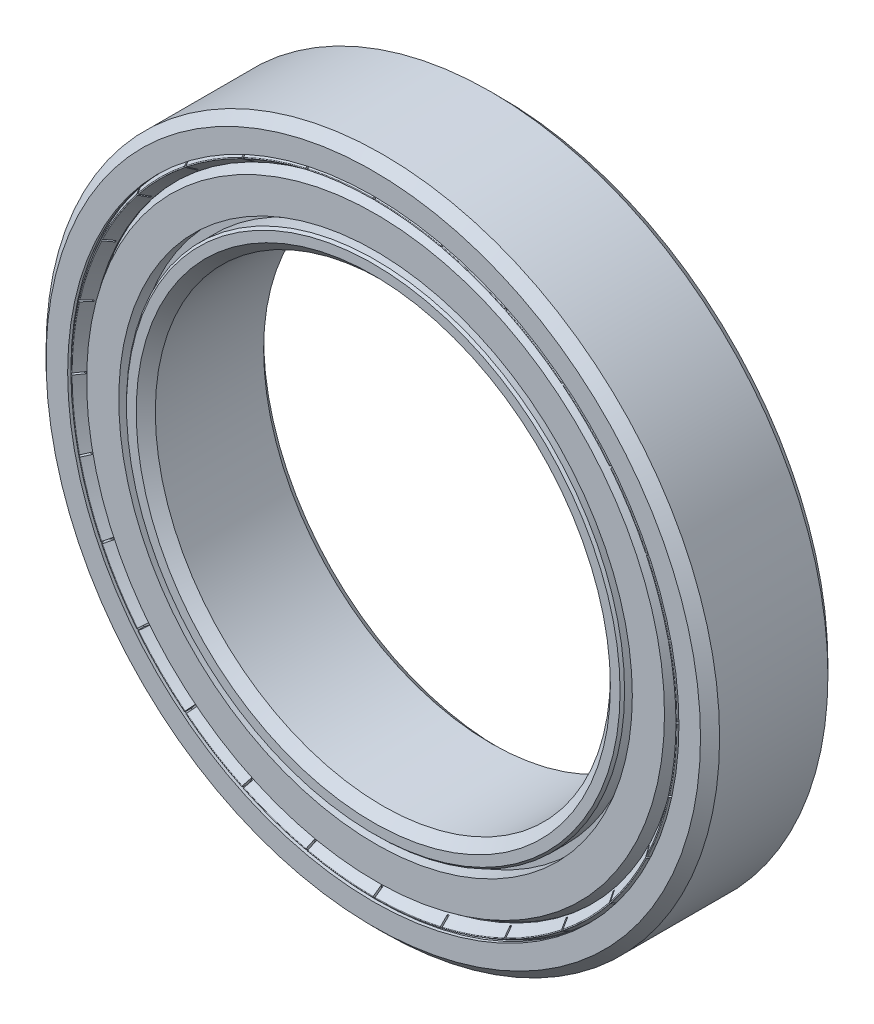
from build123d import *

# Parameters (mm, degrees)
CIRPATTERN1_COUNT  = 14
FILLET1_R          = 0.035
CUT_EXTRUDE1_START = 2.995758
CUT_EXTRUDE1_DEPTH = 1.504242
CIRPATTERN2_COUNT  = 28


with BuildPart() as part:
    # Sketch3 → Revolve1 (revolve)
    with BuildSketch(Plane(origin=(0, 0, 0), x_dir=(0, 0, -1), z_dir=(1, 0, 0))):
        with BuildLine():
            Line((2.975, 18.5), (-2.975, 18.5))
            Line((-2.975, 18.5), (-3.5, 17.975))
            Line((-3.5, 17.975), (-3.5, 16.789819322))
            Line((-3.5, 16.789819322), (-3.325, 16.789819322))
            Line((-3.325, 16.789819322), (-3.325, 17.194909661))
            Line((-3.325, 17.194909661), (-3.201256313, 17.318653348))
            Line((-3.201256313, 17.318653348), (-1.05, 17.318653348))
            ThreePointArc((-1.05, 17.318653348), (0, 17.6), (1.05, 17.318653348))
            Line((1.05, 17.318653348), (3.201256313, 17.318653348))
            Line((3.201256313, 17.318653348), (3.325, 17.194909661))
            Line((3.325, 17.194909661), (3.325, 16.789819322))
            Line((3.325, 16.789819322), (3.5, 16.789819322))
            Line((3.5, 16.789819322), (3.5, 17.975))
            Line((3.5, 17.975), (2.975, 18.5))
        make_face()
        with BuildLine():
            Line((2.975, 12.5), (-2.975, 12.5))
            Line((-2.975, 12.5), (-3.5, 13.025))
            Line((-3.5, 13.025), (-3.5, 13.557602965))
            Line((-3.5, 13.557602965), (-3.376256313, 13.681346652))
            Line((-3.376256313, 13.681346652), (-1.05, 13.681346652))
            ThreePointArc((-1.05, 13.681346652), (0, 13.4), (1.05, 13.681346652))
            Line((1.05, 13.681346652), (3.376256313, 13.681346652))
            Line((3.376256313, 13.681346652), (3.5, 13.557602965))
            Line((3.5, 13.557602965), (3.5, 13.025))
            Line((3.5, 13.025), (2.975, 12.5))
        make_face()
    revolve(axis=Axis((0, 0, 3.5), (0, 0, -1)))


with BuildPart() as body_2:
    # Sketch4 → Revolve2 (revolve)
    with BuildSketch(Plane(origin=(0, 0, 0), x_dir=(0, 0, -1), z_dir=(1, 0, 0))):
        with BuildLine():
            Line((0, 17.6), (0, 13.4))
            ThreePointArc((0, 13.4), (-2.1, 15.5), (0, 17.6))
        make_face()
    revolve(axis=Axis((0, 18.5, 0), (0, -1, 0)))


with BuildPart() as cirpattern1_1:
    # CirPattern1: pattern copy
    add(body_2.part.rotate(Axis((0, 0, 0), (0, 0, 1)), 1 * 360 / CIRPATTERN1_COUNT))


with BuildPart() as cirpattern1_2:
    # CirPattern1: pattern copy
    add(body_2.part.rotate(Axis((0, 0, 0), (0, 0, 1)), 2 * 360 / CIRPATTERN1_COUNT))


with BuildPart() as cirpattern1_3:
    # CirPattern1: pattern copy
    add(body_2.part.rotate(Axis((0, 0, 0), (0, 0, 1)), 3 * 360 / CIRPATTERN1_COUNT))


with BuildPart() as cirpattern1_4:
    # CirPattern1: pattern copy
    add(body_2.part.rotate(Axis((0, 0, 0), (0, 0, 1)), 4 * 360 / CIRPATTERN1_COUNT))


with BuildPart() as cirpattern1_5:
    # CirPattern1: pattern copy
    add(body_2.part.rotate(Axis((0, 0, 0), (0, 0, 1)), 5 * 360 / CIRPATTERN1_COUNT))


with BuildPart() as cirpattern1_6:
    # CirPattern1: pattern copy
    add(body_2.part.rotate(Axis((0, 0, 0), (0, 0, 1)), 6 * 360 / CIRPATTERN1_COUNT))


with BuildPart() as cirpattern1_7:
    # CirPattern1: pattern copy
    add(body_2.part.rotate(Axis((0, 0, 0), (0, 0, 1)), 7 * 360 / CIRPATTERN1_COUNT))


with BuildPart() as cirpattern1_8:
    # CirPattern1: pattern copy
    add(body_2.part.rotate(Axis((0, 0, 0), (0, 0, 1)), 8 * 360 / CIRPATTERN1_COUNT))


with BuildPart() as cirpattern1_9:
    # CirPattern1: pattern copy
    add(body_2.part.rotate(Axis((0, 0, 0), (0, 0, 1)), 9 * 360 / CIRPATTERN1_COUNT))


with BuildPart() as cirpattern1_10:
    # CirPattern1: pattern copy
    add(body_2.part.rotate(Axis((0, 0, 0), (0, 0, 1)), 10 * 360 / CIRPATTERN1_COUNT))


with BuildPart() as cirpattern1_11:
    # CirPattern1: pattern copy
    add(body_2.part.rotate(Axis((0, 0, 0), (0, 0, 1)), 11 * 360 / CIRPATTERN1_COUNT))


with BuildPart() as cirpattern1_12:
    # CirPattern1: pattern copy
    add(body_2.part.rotate(Axis((0, 0, 0), (0, 0, 1)), 12 * 360 / CIRPATTERN1_COUNT))


with BuildPart() as cirpattern1_13:
    # CirPattern1: pattern copy
    add(body_2.part.rotate(Axis((0, 0, 0), (0, 0, 1)), 13 * 360 / CIRPATTERN1_COUNT))


with BuildPart() as body_16:
    # Sketch5 → Revolve3 (revolve)
    with BuildSketch(Plane(origin=(0, 0, 0), x_dir=(0, 0, -1), z_dir=(1, 0, 0))):
        Polygon((-2.1, 13.681346652), (-2.525418771, 13.681346652), (-2.525418771, 14.106765423), (-3.376256313, 14.106765423), (-3.376256313, 15.873169267), (-2.525418771, 16.364400551), (-2.1, 16.364400551), align=None)
        Polygon((2.525418771, 16.364400551), (2.1, 16.364400551), (2.1, 13.681346652), (2.525418771, 13.681346652), (2.525418771, 14.106765423), (3.376256313, 14.106765423), (3.376256313, 15.873169267), align=None)
    revolve(axis=Axis((0, 0, 3.5), (0, 0, -1)))


with BuildPart() as body_17:
    # Sketch6 → Revolve4 (revolve)
    with BuildSketch(Plane(origin=(0, 0, 0), x_dir=(0, 0, -1), z_dir=(1, 0, 0))):
        Polygon((-2.797765893, 16.789819322), (-3.19375, 16.789819322), (-3.5, 16.613005803), (-2.902765893, 16.194817979), (-2.867765893, 16.194817979), (-2.797765893, 16.207160867), align=None)
    revolve(axis=Axis((0, 0, 3.5), (0, 0, -1)))

    # Fillet1
    fillet1_edges = [body_17.edges().sort_by_distance(p)[0] for p in [
        (0, -16.613005803, 3.5),
    ]]
    fillet(fillet1_edges, radius=FILLET1_R)

    # Sketch7 → Cut-Extrude1 (cut, through all)
    with BuildSketch(Plane.XY.offset(CUT_EXTRUDE1_START)):
        Polygon((-0.05, 16.789819322), (-0.05, 16.889819322), (0.05, 16.889819322), (0.05, 16.789819322), (0.05, 16.194817979), (0.05, 16.094817979), (-0.05, 16.094817979), (-0.05, 16.194817979), align=None)
    cut_extrude1 = extrude(amount=CUT_EXTRUDE1_DEPTH, mode=Mode.SUBTRACT)

    # CirPattern2: Cut-Extrude1 ×28 about axis
    cirpattern2_axis = Axis((0, 0, 0), (0, 0, 1))
    for i in range(1, CIRPATTERN2_COUNT):
        add(cut_extrude1.rotate(cirpattern2_axis, i * 360 / CIRPATTERN2_COUNT), mode=Mode.SUBTRACT)


with BuildPart() as body_18:
    # Mirror1: mirrored copy
    add(body_17.part.mirror(Plane.XY))


solid = Compound([part.part, body_2.part, cirpattern1_1.part, cirpattern1_2.part, cirpattern1_3.part, cirpattern1_4.part, cirpattern1_5.part, cirpattern1_6.part, cirpattern1_7.part, cirpattern1_8.part, cirpattern1_9.part, cirpattern1_10.part, cirpattern1_11.part, cirpattern1_12.part, cirpattern1_13.part, body_16.part, body_17.part, body_18.part])
